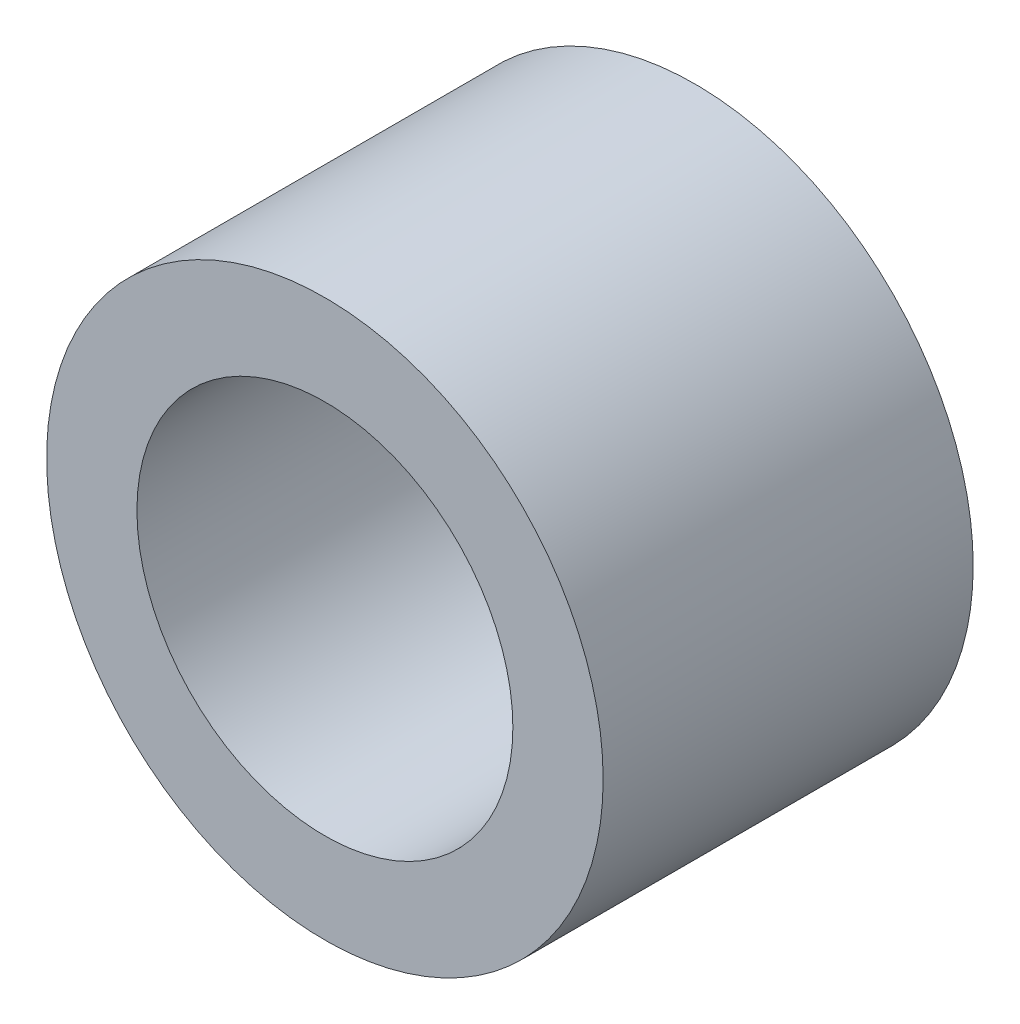
from build123d import *

# Parameters (mm, degrees)
SKETCH1_R      = 4.7752
SKETCH1_R_2    = 3.2258
EXTRUDE1_DEPTH = 3.175


with BuildPart() as part:
    # Sketch1 → Extrude1 (new body, symmetric)
    with BuildSketch(Plane.XY):
        Circle(SKETCH1_R)
        Circle(SKETCH1_R_2, mode=Mode.SUBTRACT)
    extrude(amount=EXTRUDE1_DEPTH, both=True)


solid = part.part
